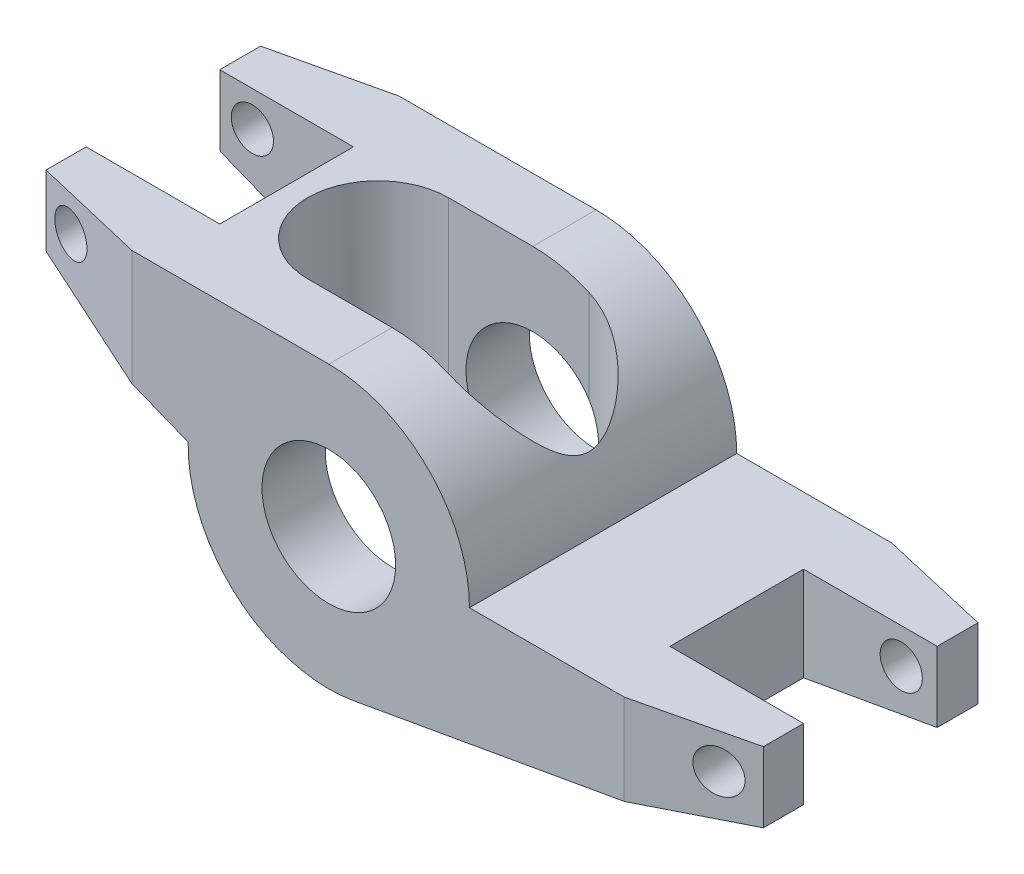
from build123d import *

# Parameters (mm, degrees)
SKETCH1_R               = 4.75
BOSS_EXTRUDE1_DEPTH     = 9.5
SKETCH2_W               = 19
SKETCH2_H               = 9.5
CUT_EXTRUDE1_DEPTH      = 11
CUT_EXTRUDE1_DEPTH_BACK = 11
CHAMFER1_SIZE           = 8
CHAMFER1_SIZE2          = 1.895543273
CHAMFER2_SIZE           = 8
CHAMFER2_SIZE2          = 1.846945529
SKETCH5_R               = 1.5
CUT_EXTRUDE2_DEPTH      = 10.5000001
CUT_EXTRUDE2_DEPTH_BACK = 10.5000001


with BuildPart() as part:
    # Sketch1 → Boss-Extrude1 (new body, symmetric)
    with BuildSketch(Plane.XY):
        with BuildLine():
            Line((0, 10), (-22, 10))
            Line((-22, 10), (-22, 5))
            Line((-22, 5), (-9.9979998, 0.2))
            ThreePointArc((-9.9979998, 0.2), (-6.49865122, -7.600495531), (1.750767609, -9.845547866))
            Line((1.750767609, -9.845547866), (29, -5))
            Line((29, -5), (29, 0))
            Line((29, 0), (10, 0))
            ThreePointArc((10, 0), (7.071067812, 7.071067812), (0, 10))
        make_face()
        Circle(SKETCH1_R, mode=Mode.SUBTRACT)
    extrude(amount=BOSS_EXTRUDE1_DEPTH, both=True)

    # Sketch2 → Cut-Extrude1 (cut, two sides)
    with BuildSketch(Plane(origin=(0, 0, 0), x_dir=(1, 0, 0), z_dir=(0, 1, 0))) as cut_extrude1_sk:
        with Locations((-22, 0)):
            Rectangle(SKETCH2_W, SKETCH2_H)
        with Locations((29, 0)):
            Rectangle(SKETCH2_W, SKETCH2_H)
        with BuildLine():
            Line((-6, 5), (4, 5))
            ThreePointArc((4, 5), (9, 0), (4, -5))
            Line((4, -5), (-6, -5))
            ThreePointArc((-6, -5), (-11, 0), (-6, 5))
        make_face()
    extrude(amount=CUT_EXTRUDE1_DEPTH, mode=Mode.SUBTRACT)
    extrude(cut_extrude1_sk.sketch, amount=-CUT_EXTRUDE1_DEPTH_BACK, mode=Mode.SUBTRACT)

    # Chamfer1
    chamfer1_edges = [part.edges().sort_by_distance(p)[0] for p in [
        (-22, 7.5, 9.5),
        (29, -2.5, 9.5),
    ]]
    chamfer1_side = [part.faces().sort_by_distance(p)[0] for p in [
        (6.683704933, 6.683704933, 9.5),
    ]]
    chamfer(chamfer1_edges, length=CHAMFER1_SIZE, length2=CHAMFER1_SIZE2, reference=chamfer1_side[0])

    # Chamfer2
    chamfer2_edges = [part.edges().sort_by_distance(p)[0] for p in [
        (-22, 7.5, -9.5),
        (29, -2.5, -9.5),
    ]]
    chamfer2_side = [part.faces().sort_by_distance(p)[0] for p in [
        (6.683704933, 6.683704933, -9.5),
    ]]
    chamfer(chamfer2_edges, length=CHAMFER2_SIZE, length2=CHAMFER2_SIZE2, reference=chamfer2_side[0])

    # Sketch5 → Cut-Extrude2 (cut, two sides)
    with BuildSketch(Plane.XY) as cut_extrude2_sk:
        with Locations((-19.684598733, 7.5)):
            Circle(SKETCH5_R)
        with Locations((26.44619669, -2.5)):
            Circle(SKETCH5_R)
    extrude(amount=CUT_EXTRUDE2_DEPTH, mode=Mode.SUBTRACT)
    extrude(cut_extrude2_sk.sketch, amount=-CUT_EXTRUDE2_DEPTH_BACK, mode=Mode.SUBTRACT)


solid = part.part
